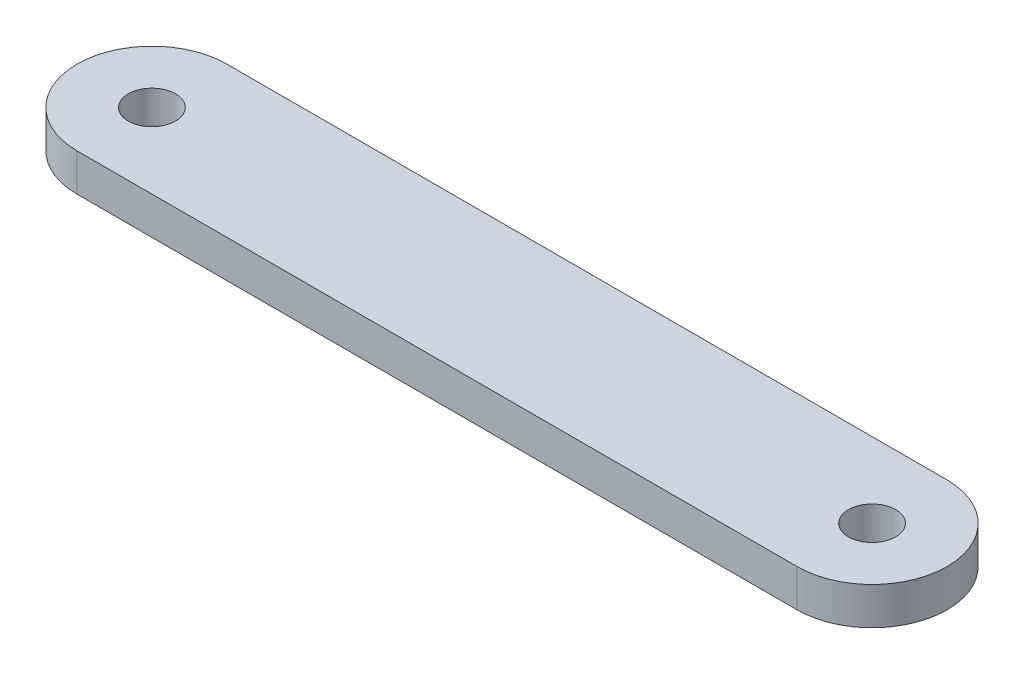
from build123d import *

# Parameters (mm, degrees)
SKETCH1_R           = 2.000000064
BOSS_EXTRUDE1_DEPTH = 3.175


with BuildPart() as part:
    # Sketch1 → Boss-Extrude1 (new body)
    with BuildSketch(Plane(origin=(0, 0, 0), x_dir=(1, 0, 0), z_dir=(0, 1, 0))):
        with BuildLine():
            Line((-30.48, 6.35), (30.48, 6.35))
            ThreePointArc((30.48, 6.35), (36.83, 0), (30.48, -6.35))
            Line((30.48, -6.35), (-30.48, -6.35))
            ThreePointArc((-30.48, -6.35), (-36.83, 0), (-30.48, 6.35))
        make_face()
        with Locations((-30.48, 0)):
            Circle(SKETCH1_R, mode=Mode.SUBTRACT)
        with Locations((30.48, 0)):
            Circle(SKETCH1_R, mode=Mode.SUBTRACT)
    extrude(amount=BOSS_EXTRUDE1_DEPTH)


solid = part.part
